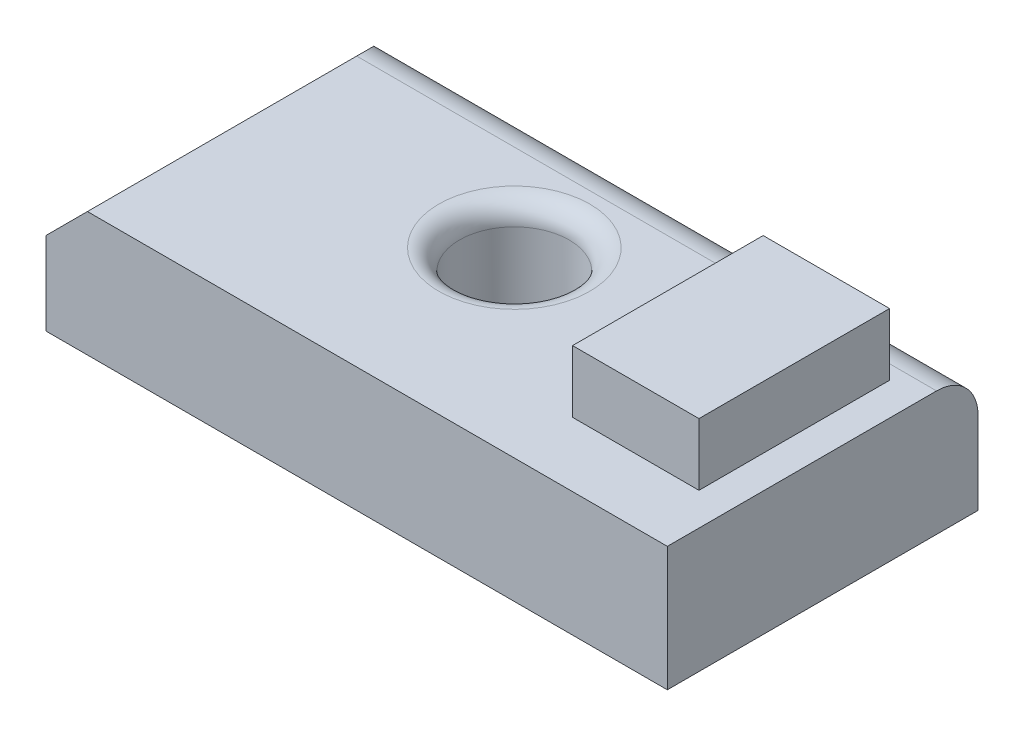
from build123d import *

# Parameters (mm, degrees)
SKETCH1_W           = 3810
SKETCH1_H           = 1905
BOSS_EXTRUDE1_DEPTH = 762
SKETCH2_R           = 336.258211588
CUT_EXTRUDE1_DEPTH  = 763
SKETCH3_W           = 775.150416673
SKETCH3_H           = 1168.813193726
BOSS_EXTRUDE2_DEPTH = 381
FILLET1_R           = 127
CHAMFER3_SIZE       = 254
FILLET3_R           = 254
CHAMFER4_SIZE       = 254


with BuildPart() as part:
    # Sketch1 → Boss-Extrude1 (new body)
    with BuildSketch(Plane(origin=(0, 0, 0), x_dir=(1, 0, 0), z_dir=(0, 1, 0))):
        with Locations((1562.626728111, 175.576036866)):
            Rectangle(SKETCH1_W, SKETCH1_H)
    extrude(amount=BOSS_EXTRUDE1_DEPTH)

    # Sketch2 → Cut-Extrude1 (cut, through all)
    with BuildSketch(Plane(origin=(0, 762, 0), x_dir=(1, 0, 0), z_dir=(0, 1, 0))):
        with Locations((1412.4667322, 339.940416015)):
            Circle(SKETCH2_R)
    extrude(amount=-CUT_EXTRUDE1_DEPTH, mode=Mode.SUBTRACT)

    # Sketch3 → Boss-Extrude2 (add)
    with BuildSketch(Plane(origin=(0, 762, 0), x_dir=(1, 0, 0), z_dir=(0, 1, 0))):
        with Locations((2879.570760626, 201.955501308)):
            Rectangle(SKETCH3_W, SKETCH3_H)
    extrude(amount=BOSS_EXTRUDE2_DEPTH)

    # Fillet1
    fillet1_edges = [part.edges().sort_by_distance(p)[0] for p in [
        (1076.208520612, 762, -339.940416015),
    ]]
    fillet(fillet1_edges, radius=FILLET1_R)

    # Chamfer3
    chamfer3_edges = [part.edges().sort_by_distance(p)[0] for p in [
        (-342.373271889, 381, -1128.076036866),
    ]]
    chamfer(chamfer3_edges, length=CHAMFER3_SIZE)

    # Fillet3
    fillet3_edges = [part.edges().sort_by_distance(p)[0] for p in [
        (1689.626728111, 762, -1128.076036866),
    ]]
    fillet(fillet3_edges, radius=FILLET3_R)

    # Chamfer4
    chamfer4_edges = [part.edges().sort_by_distance(p)[0] for p in [
        (-342.373271889, 762, -48.576036866),
    ]]
    chamfer(chamfer4_edges, length=CHAMFER4_SIZE)


solid = part.part
